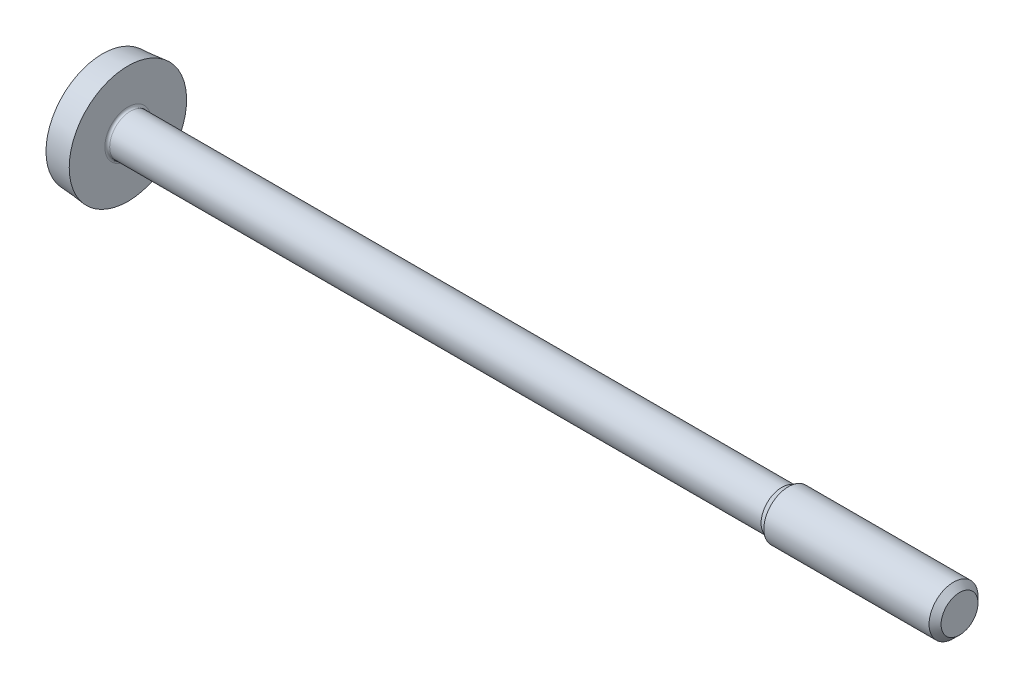
from build123d import *

# Parameters (mm, degrees)
CUT_EXTRUDE1_DEPTH = 0.6


with BuildPart() as part:
    # Sketch1 → Revolve1 (revolve)
    with BuildSketch(Plane.XY):
        with BuildLine():
            Line((-1.04, 2.30901179), (0, 2.4))
            Line((0, 2.4), (0, 0.945))
            ThreePointArc((0, 0.945), (0.029289322, 0.874289322), (0.1, 0.845))
            Line((0.1, 0.845), (26.731532125, 0.845))
            Line((26.731532125, 0.845), (27, 1))
            Line((27, 1), (33.7545, 1))
            Line((33.7545, 1), (34, 0.7545))
            Line((34, 0.7545), (34, 0))
            Line((34, 0), (-1.6, 0))
            ThreePointArc((-1.6, 0), (-1.457999714, 1.187974689), (-1.04, 2.30901179))
        make_face()
    revolve(axis=Axis((34, 0, 0), (-1, 0, 0)))

    # Sketch2 → Cut-Extrude1 (cut)
    with BuildSketch(Plane(origin=(-1.04, 0, 0), x_dir=(0, 0, -1), z_dir=(1, 0, 0))):
        Polygon((-1, 0.29), (-1, -0.29), (-0.29, -0.29), (-0.29, -2.5), (0.29, -2.5), (0.29, -0.29), (1, -0.29), (1, 0.29), (0.29, 0.29), (0.29, 2.5), (-0.29, 2.5), (-0.29, 0.29), align=None)
    extrude(amount=-CUT_EXTRUDE1_DEPTH, mode=Mode.SUBTRACT)


solid = part.part
